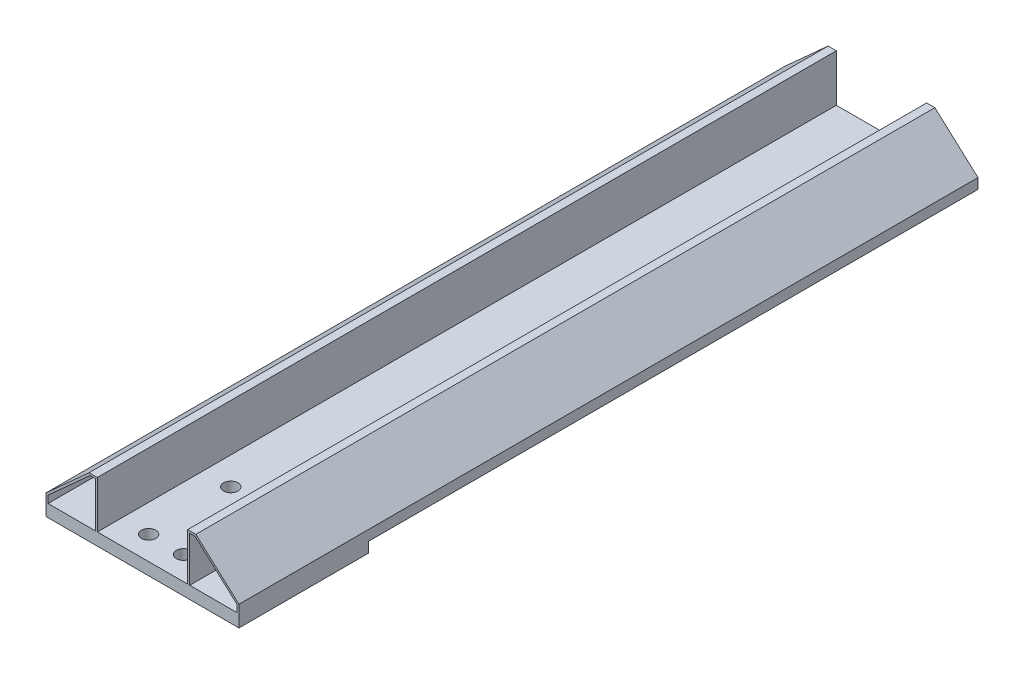
from build123d import *

# Parameters (mm, degrees)
CROQUIS2_W              = 94
CROQUIS2_H              = 24
SALIENTE_EXTRUIR1_DEPTH = 360
CROQUIS4_W              = 44
CROQUIS4_H              = 23
CORTAR_EXTRUIR2_DEPTH   = 360
CORTAR_EXTRUIR3_DEPTH   = 360
CORTAR_EXTRUIR5_DEPTH   = 360
CROQUIS8_W              = 94
CROQUIS8_H              = 63
SALIENTE_EXTRUIR2_DEPTH = 5
CROQUIS9_R              = 3.5
CORTAR_EXTRUIR6_DEPTH   = 30


with BuildPart() as part:
    # Croquis2 → Saliente-Extruir1 (new body)
    with BuildSketch(Plane.XY):
        with Locations((47, -12)):
            Rectangle(CROQUIS2_W, CROQUIS2_H)
    extrude(amount=SALIENTE_EXTRUIR1_DEPTH)

    # Croquis4 → Cortar-Extruir2 (cut)
    with BuildSketch(Plane(origin=(0, 0, 0), x_dir=(-1, 0, 0), z_dir=(0, 0, -1))):
        Polygon((-94, 0), (-94, -19), (-73, 0), align=None)
        with Locations((-47, -11.5)):
            Rectangle(CROQUIS4_W, CROQUIS4_H)
        Polygon((0, 0), (-21, 0), (0, -19), align=None)
    extrude(amount=-CORTAR_EXTRUIR2_DEPTH, mode=Mode.SUBTRACT)

    # Croquis6 → Cortar-Extruir3 (cut)
    with BuildSketch(Plane(origin=(0, 0, 0), x_dir=(-1, 0, 0), z_dir=(0, 0, -1))):
        Polygon((-70, -23), (-70, -1), (-72.614757657, -1), (-93, -19.443790691), (-93, -23), align=None)
    extrude(amount=-CORTAR_EXTRUIR3_DEPTH, mode=Mode.SUBTRACT)

    # Croquis7 → Cortar-Extruir5 (cut)
    with BuildSketch(Plane(origin=(0, 0, 0), x_dir=(-1, 0, 0), z_dir=(0, 0, -1))):
        Polygon((-1, -19.443790691), (-21.385242343, -1), (-24, -1), (-24, -23), (-1, -23), align=None)
    extrude(amount=-CORTAR_EXTRUIR5_DEPTH, mode=Mode.SUBTRACT)

    # Croquis8 → Saliente-Extruir2 (add)
    with BuildSketch(Plane.XZ.offset(24)):
        with Locations((47, 328.5)):
            Rectangle(CROQUIS8_W, CROQUIS8_H)
    extrude(amount=SALIENTE_EXTRUIR2_DEPTH)

    # Croquis9 → Cortar-Extruir6 (cut, through all)
    with BuildSketch(Plane.XZ.offset(29)):
        with Locations((38.5, 348.5)):
            Circle(CROQUIS9_R)
        with Locations((55.5, 348.5)):
            Circle(CROQUIS9_R)
        with Locations((38.5, 308.5)):
            Circle(CROQUIS9_R)
        with Locations((55.5, 308.5)):
            Circle(CROQUIS9_R)
    extrude(amount=-CORTAR_EXTRUIR6_DEPTH, mode=Mode.SUBTRACT)


solid = part.part
